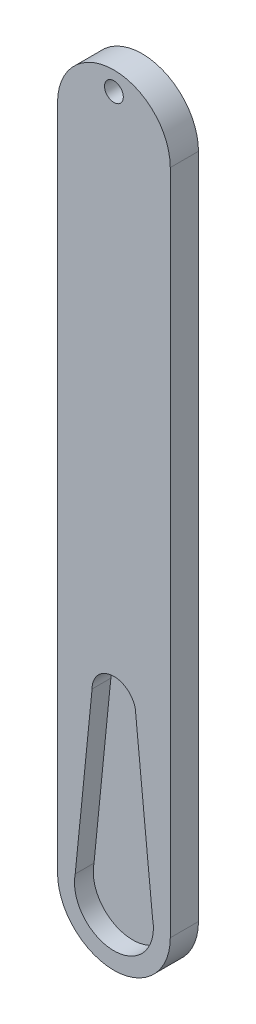
from build123d import *

# Parameters (mm, degrees)
BOSS_EXTRUDE1_DEPTH = 3
BOSS_EXTRUDE2_DEPTH = 1
SKETCH2_R           = 1
CUT_EXTRUDE1_DEPTH  = 84.91662529


with BuildPart() as part:
    # Sketch1 → Boss-Extrude1 (new body)
    with BuildSketch(Plane.XY):
        with BuildLine():
            Line((0, 83), (0, 6))
            ThreePointArc((0, 6), (1.757359313, 1.757359313), (6, 0))
            ThreePointArc((6, 0), (10.242640687, 1.757359313), (12, 6))
            Line((12, 6), (12, 83))
            Line((12, 83), (0, 83))
        make_face()
        with BuildLine():
            Line((1.882949163, 6.83059762), (3.675, 24.775))
            ThreePointArc((3.675, 24.775), (6, 27.1), (8.325, 24.775))
            Line((8.325, 24.775), (10.117050837, 6.83059762))
            ThreePointArc((10.117050837, 6.83059762), (6, 1.8), (1.882949163, 6.83059762))
        make_face(mode=Mode.SUBTRACT)
    extrude(amount=BOSS_EXTRUDE1_DEPTH)

    # Sketch1_3 → Boss-Extrude2 (add)
    with BuildSketch(Plane.XY):
        with BuildLine():
            ThreePointArc((8.325, 24.775), (6, 27.1), (3.675, 24.775))
            Line((3.675, 24.775), (1.882949163, 6.83059762))
            ThreePointArc((1.882949163, 6.83059762), (6, 1.8), (10.117050837, 6.83059762))
            Line((10.117050837, 6.83059762), (8.325, 24.775))
        make_face()
    extrude(amount=BOSS_EXTRUDE2_DEPTH)

    # Sketch2 → Cut-Extrude1 (cut, through all)
    with BuildSketch(Plane.XY.offset(3)):
        with BuildLine():
            Line((12, 83), (6, 83))
            ThreePointArc((6, 83), (10.242640687, 81.242640687), (12, 77))
            Line((12, 77), (12, 83))
        make_face()
        with BuildLine():
            Line((0, 83), (0, 77))
            ThreePointArc((0, 77), (1.757359313, 81.242640687), (6, 83))
            Line((6, 83), (0, 83))
        make_face()
        with Locations((6, 81)):
            Circle(SKETCH2_R)
    extrude(amount=-CUT_EXTRUDE1_DEPTH, mode=Mode.SUBTRACT)


solid = part.part
